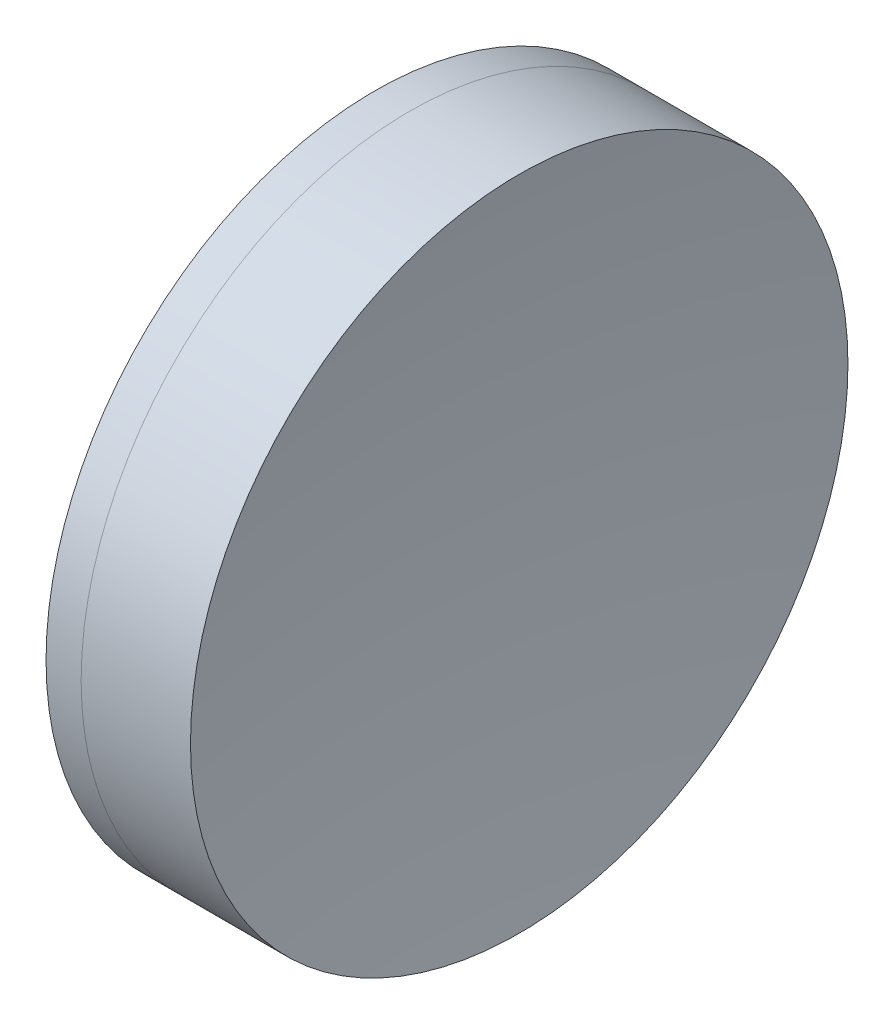
from build123d import *


with BuildPart() as part:
    # 草图1 one side → 旋转1 (revolve)
    with BuildSketch(Plane(origin=(0, 0, 0), x_dir=(1, 0, 0), z_dir=(0, 1, 0)), mode=Mode.PRIVATE) as revolve_1_sk:
        with BuildLine():
            ThreePointArc((352.501569273, 12.7), (351.49322027, 6.385549222), (351.155851818, 0))
            Line((351.155851818, 0), (355.155851818, 0))
            ThreePointArc((355.155851818, 0), (354.830353407, 6.383110635), (353.857235041, 12.7))
            Line((353.857235041, 12.7), (352.501569273, 12.7))
        make_face()
    revolve(revolve_1_sk.sketch.rotate(Axis((124.523309526, 0, 0), (1, 0, 0)), 180), axis=Axis((124.523309526, 0, 0), (1, 0, 0)))  # turned: the seam where the file's is


with BuildPart() as body_2:
    # 草图2 one side → 旋转3 (revolve)
    with BuildSketch(Plane(origin=(0, 0, 0), x_dir=(1, 0, 0), z_dir=(0, 1, 0)), mode=Mode.PRIVATE) as revolve_3_sk:
        with BuildLine():
            Line((358.081666208, 12.7), (353.857235041, 12.7))
            ThreePointArc((353.857235041, 12.7), (354.830353407, 6.383110635), (355.155851818, 0))
            Line((355.155851818, 0), (357.155851818, 0))
            ThreePointArc((357.155851818, 0), (357.387612101, 6.366850326), (358.081666208, 12.7))
        make_face()
    revolve(revolve_3_sk.sketch.rotate(Axis((-0.551919993, 0, 0), (1, 0, 0)), 180), axis=Axis((-0.551919993, 0, 0), (1, 0, 0)))  # turned: the seam where the file's is


solid = Compound([part.part, body_2.part])
